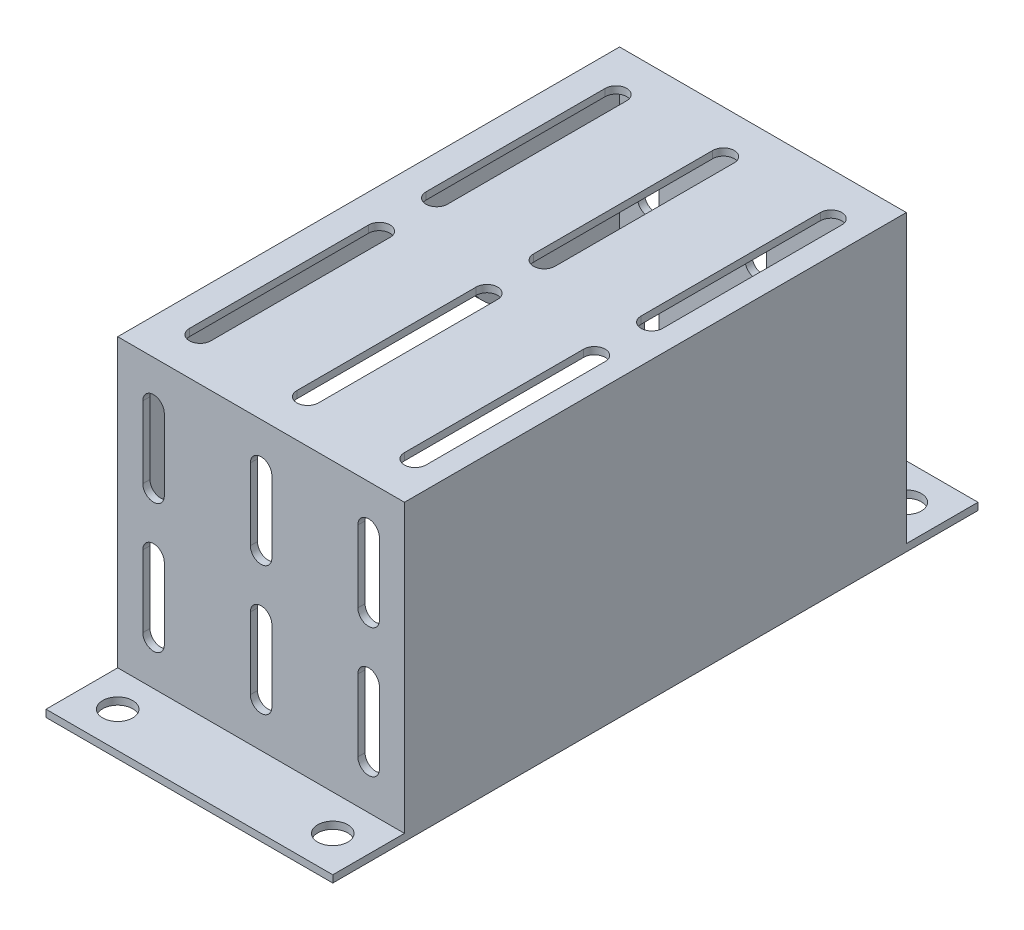
from build123d import *

# Parameters (mm, degrees)
EXTRUDE_1_DEPTH        = 40
SKETCH_2_W             = 70
SKETCH_2_H             = 41
EXTRUDE_2_DEPTH        = 1
SKETCH_3_W             = 70
SKETCH_3_H             = 41
EXTRUDE_3_DEPTH        = 1
SKETCH_4_R             = 2.1
CUT_EXTRUDE_1_DEPTH    = 1
CUT_EXTRUDE_2_DEPTH    = 1
CUT_EXTRUDE_3_DEPTH    = 81
PATTERN_LINEAR_1_COUNT = 3
PATTERN_LINEAR_1_PITCH = 15
CUT_EXTRUDE_4_DEPTH    = 1
PATTERN_LINEAR_2_COUNT = 3
PATTERN_LINEAR_2_PITCH = 15
SKETCH_8_W             = 68
SKETCH_8_H             = 18
CUT_EXTRUDE_5_DEPTH    = 10
FILLET_1_R             = 10


with BuildPart() as part:
    # 草图1 → 凸台-拉伸1 (new body)
    with BuildSketch(Plane(origin=(0, 0, 0), x_dir=(0, 0, -1), z_dir=(1, 0, 0))):
        Polygon((0, 0), (10, 0), (10, 40), (80, 40), (80, 0), (90, 0), (90, -1), (79, -1), (79, 39), (11, 39), (11, -1), (0, -1), align=None)
    extrude(amount=EXTRUDE_1_DEPTH)

    # 草图2 → 凸台-拉伸2 (add)
    with BuildSketch(Plane(origin=(40, 0, 0), x_dir=(0, 0, -1), z_dir=(1, 0, 0))):
        with Locations((45, 19.5)):
            Rectangle(SKETCH_2_W, SKETCH_2_H)
    extrude(amount=-EXTRUDE_2_DEPTH)

    # 草图3 → 凸台-拉伸3 (add)
    with BuildSketch(Plane.ZY):
        with Locations((-45, 19.5)):
            Rectangle(SKETCH_3_W, SKETCH_3_H)
    extrude(amount=-EXTRUDE_3_DEPTH)

    # 草图4 → 切除-拉伸1 (cut)
    with BuildSketch(Plane(origin=(0, 0, 0), x_dir=(1, 0, 0), z_dir=(0, 1, 0))):
        with Locations((5, 85)):
            Circle(SKETCH_4_R)
        with Locations((35, 85)):
            Circle(SKETCH_4_R)
        with Locations((35, 5)):
            Circle(SKETCH_4_R)
        with Locations((5, 5)):
            Circle(SKETCH_4_R)
    extrude(amount=-CUT_EXTRUDE_1_DEPTH, mode=Mode.SUBTRACT)

    # 草图5 → 切除-拉伸2 (cut)
    with BuildSketch(Plane.ZY):
        with BuildLine():
            Line((-30, 15), (-30, -16.50263466))
            ThreePointArc((-30, -16.50263466), (-45, -31.50263466), (-60, -16.50263466))
            Line((-60, -16.50263466), (-60, 15))
            ThreePointArc((-60, 15), (-45, 30), (-30, 15))
        make_face()
    extrude(amount=-CUT_EXTRUDE_2_DEPTH, mode=Mode.SUBTRACT)

    # 草图6 → 切除-拉伸3 (cut, through all)
    with BuildSketch(Plane.XY.offset(-10)):
        with BuildLine():
            Line((6.5, 34), (6.5, 24))
            ThreePointArc((6.5, 24), (5, 22.5), (3.5, 24))
            Line((3.5, 24), (3.5, 34))
            ThreePointArc((3.5, 34), (5, 35.5), (6.5, 34))
        make_face()
        with BuildLine():
            Line((6.5, 16), (6.5, 6))
            ThreePointArc((6.5, 6), (5, 4.5), (3.5, 6))
            Line((3.5, 6), (3.5, 16))
            ThreePointArc((3.5, 16), (5, 17.5), (6.5, 16))
        make_face()
    cut_extrude_3 = extrude(amount=-CUT_EXTRUDE_3_DEPTH, mode=Mode.SUBTRACT)

    # 阵列(线性)1: 切除-拉伸3 ×3
    with Locations(*[(i * PATTERN_LINEAR_1_PITCH, 0, 0) for i in range(1, PATTERN_LINEAR_1_COUNT)]):
        add(cut_extrude_3, mode=Mode.SUBTRACT)

    # 草图7 → 切除-拉伸4 (cut)
    with BuildSketch(Plane(origin=(0, 40, 0), x_dir=(1, 0, 0), z_dir=(0, 1, 0))):
        with BuildLine():
            Line((7, 74), (7, 49))
            ThreePointArc((7, 49), (5.5, 47.5), (4, 49))
            Line((4, 49), (4, 74))
            ThreePointArc((4, 74), (5.5, 75.5), (7, 74))
        make_face()
        with BuildLine():
            Line((7, 41), (7, 16))
            ThreePointArc((7, 16), (5.5, 14.5), (4, 16))
            Line((4, 16), (4, 41))
            ThreePointArc((4, 41), (5.5, 42.5), (7, 41))
        make_face()
    cut_extrude_4 = extrude(amount=-CUT_EXTRUDE_4_DEPTH, mode=Mode.SUBTRACT)

    # 阵列(线性)2: 切除-拉伸4 ×3
    with Locations(*[(i * PATTERN_LINEAR_2_PITCH, 0, 0) for i in range(1, PATTERN_LINEAR_2_COUNT)]):
        add(cut_extrude_4, mode=Mode.SUBTRACT)

    # 草图8 → 切除-拉伸5 (cut)
    with BuildSketch(Plane.ZY):
        with Locations((-45, 8)):
            Rectangle(SKETCH_8_W, SKETCH_8_H)
    extrude(amount=-CUT_EXTRUDE_5_DEPTH, mode=Mode.SUBTRACT)

    # 圆角1
    fillet_1_edges = [part.edges().sort_by_distance(p)[0] for p in [
        (0.5, 17, -30.133931253),
        (0.5, 17, -59.866068747),
    ]]
    fillet(fillet_1_edges, radius=FILLET_1_R)


solid = part.part
